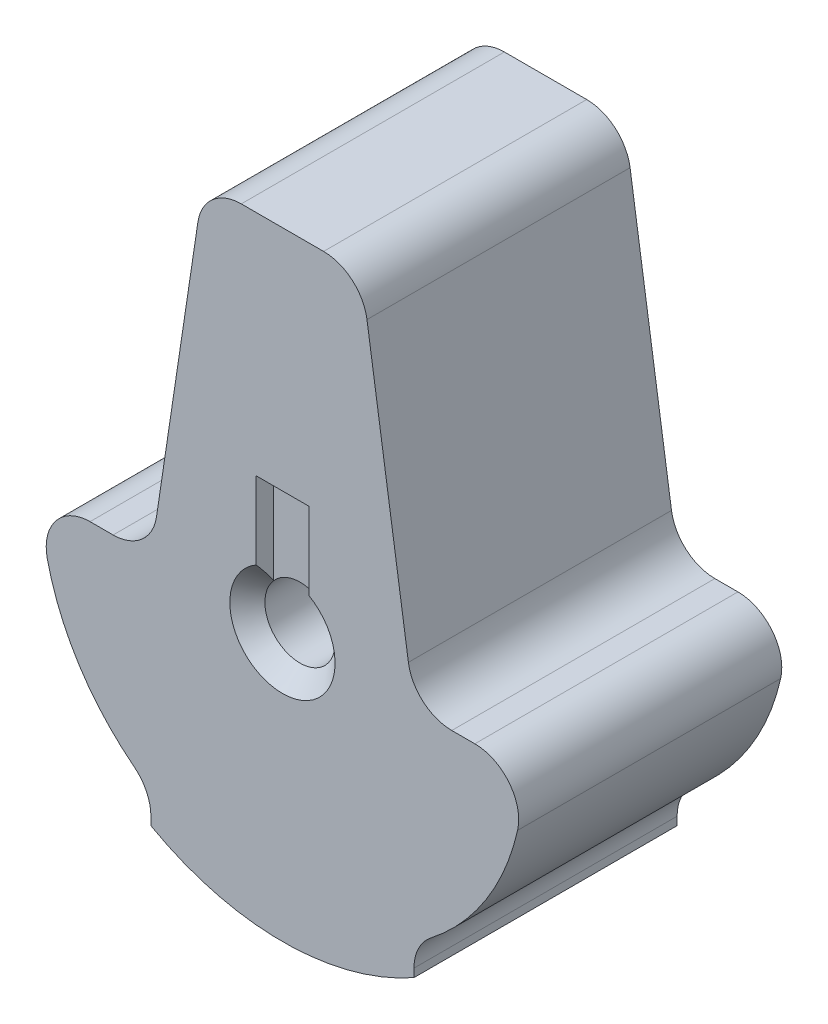
from build123d import *

# Parameters (mm, degrees)
BOSS_EXTRUDE2_DEPTH  = 7.62
CUT_EXTRUDE1_DEPTH   = 0.508
SKETCH4_W            = 1.524
SKETCH4_H            = 3.556
CUT_EXTRUDE2_DEPTH   = 0.508
BOSS_EXTRUDE8_DEPTH  = 7.62
BOSS_EXTRUDE10_DEPTH = 7.62
FILLET2_R            = 1.27
CUT_EXTRUDE4_DEPTH   = 7.62
FILLET4_R            = 1.27


with BuildPart() as part:
    # Sketch2 → Boss-Extrude2 (new body)
    with BuildSketch(Plane.XY):
        with BuildLine():
            ThreePointArc((-3.81, 0), (0, -3.81), (3.81, 0))
            Line((3.81, 0), (3.81, 8.636))
            ThreePointArc((3.81, 8.636), (3.363630735, 9.713630735), (2.286, 10.16))
            Line((2.286, 10.16), (-2.286, 10.16))
            ThreePointArc((-2.286, 10.16), (-3.363630735, 9.713630735), (-3.81, 8.636))
            Line((-3.81, 8.636), (-3.81, 0))
        make_face()
        with BuildLine():
            Line((-0.762, 0), (1.016, 0))
            ThreePointArc((1.016, 0), (-0.359210245, -0.950380976), (-0.762, 0.672020833))
            Line((-0.762, 0.672020833), (-0.762, 0))
        make_face(mode=Mode.SUBTRACT)
    extrude(amount=BOSS_EXTRUDE2_DEPTH)

    # Sketch3 → Cut-Extrude1 (cut)
    with BuildSketch(Plane.XY.offset(7.62)):
        with BuildLine():
            Line((-0.762, 0), (1.016, 0))
            ThreePointArc((1.016, 0), (0.950380976, 0.359210245), (0.762, 0.672020833))
            Line((0.762, 0.672020833), (0.762, 3.556))
            Line((0.762, 3.556), (-0.762, 3.556))
            Line((-0.762, 3.556), (-0.762, 0))
        make_face()
    extrude(amount=-CUT_EXTRUDE1_DEPTH, mode=Mode.SUBTRACT)

    # Sketch4 → Cut-Extrude2 (cut)
    with BuildSketch(Plane(origin=(0, 0, 0), x_dir=(-1, 0, 0), z_dir=(0, 0, -1))):
        with Locations((0, 1.778)):
            Rectangle(SKETCH4_W, SKETCH4_H)
    extrude(amount=-CUT_EXTRUDE2_DEPTH, mode=Mode.SUBTRACT)

    # Sketch7 → Cut-Revolve1 (revolve, cut)
    with BuildSketch(Plane(origin=(0, 0, 0), x_dir=(1, 0, 0), z_dir=(0, 1, 0))):
        Polygon((0, 0), (0, -7.62), (1.524, -7.62), (1.016, -7.112), (1.016, -0.508), (1.524, 0), align=None)
    revolve(axis=Axis((0, 0, 0), (0, 0, 1)), mode=Mode.SUBTRACT)

    # Sketch10 → Boss-Extrude8 (add)
    with BuildSketch(Plane.XY.offset(7.62)):
        with BuildLine():
            Line((-3.81, 0), (-6.985, 0))
            ThreePointArc((-6.985, 0), (0, -6.985), (6.985, 0))
            Line((6.985, 0), (3.81, 0))
            ThreePointArc((3.81, 0), (0, -3.81), (-3.81, 0))
        make_face()
    extrude(amount=-BOSS_EXTRUDE8_DEPTH)

    # Sketch14 → Boss-Extrude10 (add)
    with BuildSketch(Plane.XY.offset(7.62)):
        with BuildLine():
            ThreePointArc((3.81, -5.85441073), (0, -6.985), (-3.81, -5.85441073))
            Line((-3.81, -5.85441073), (-3.81, -6.745362036))
            ThreePointArc((-3.81, -6.745362036), (0, -7.747), (3.81, -6.745362036))
            Line((3.81, -6.745362036), (3.81, -5.85441073))
        make_face()
    extrude(amount=-BOSS_EXTRUDE10_DEPTH)

    # Fillet2
    fillet2_edges = [part.edges().sort_by_distance(p)[0] for p in [
        (-6.985, 0, 3.81),
        (6.985, 0, 3.81),
    ]]
    fillet(fillet2_edges, radius=FILLET2_R)

    # Sketch16 → Cut-Extrude4 (cut)
    with BuildSketch(Plane.XY.offset(7.62)):
        with BuildLine():
            Line((-3.81, 0), (-2.286, 10.16))
            ThreePointArc((-2.286, 10.16), (-3.363630735, 9.713630735), (-3.81, 8.636))
            Line((-3.81, 8.636), (-3.81, 0))
        make_face()
        with BuildLine():
            Line((2.286, 10.16), (3.81, 0))
            Line((3.81, 0), (3.81, 8.636))
            ThreePointArc((3.81, 8.636), (3.363630735, 9.713630735), (2.286, 10.16))
        make_face()
    extrude(amount=-CUT_EXTRUDE4_DEPTH, mode=Mode.SUBTRACT)

    # Fillet4
    fillet4_edges = [part.edges().sort_by_distance(p)[0] for p in [
        (-3.81, -5.85441073, 3.81),
        (3.81, -5.85441073, 3.81),
        (-3.81, 0, 3.81),
        (-2.286, 10.16, 3.81),
        (2.286, 10.16, 3.81),
        (3.81, 0, 3.81),
    ]]
    fillet(fillet4_edges, radius=FILLET4_R)


solid = part.part
